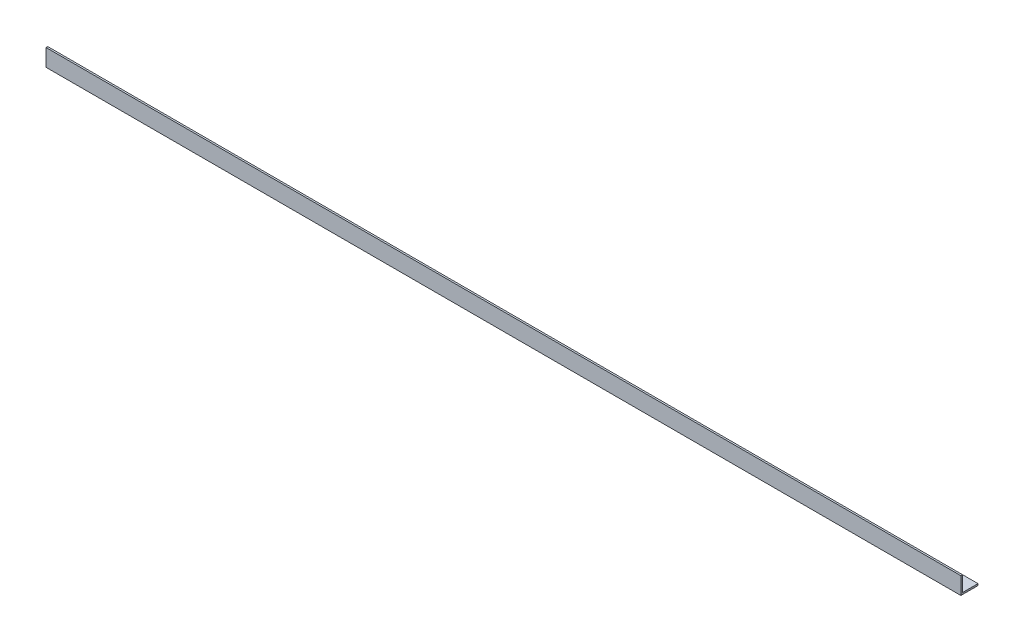
from build123d import *

# Parameters (mm, degrees)
EXTRUDE_1_DEPTH = 2665


with BuildPart() as part:
    # Эскиз1 → Вытянуть-Тонкостенный1 (new body)
    with BuildSketch(Plane(origin=(0, 0, 0), x_dir=(0, 0, -1), z_dir=(1, 0, 0))):
        Polygon((0, 50), (0, 0), (50, 0), (50, 5), (5, 5), (5, 50), align=None)
    extrude(amount=EXTRUDE_1_DEPTH)


solid = part.part
